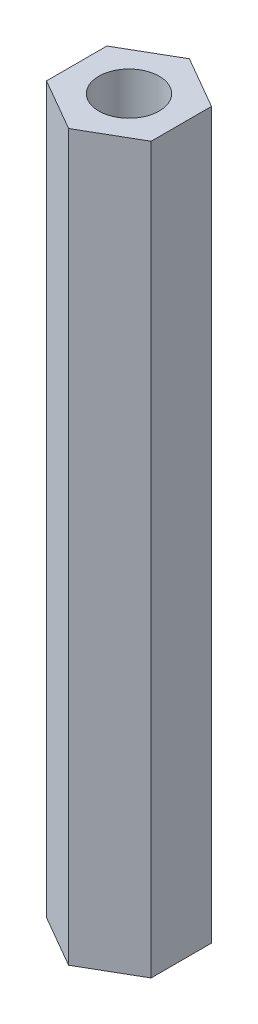
from build123d import *

# Parameters (mm, degrees)
ESQUISSE1_R      = 2.5
EXTRUSION1_DEPTH = 60


with BuildPart() as part:
    # Esquisse1 → Extrusion1 (new body)
    with BuildSketch(Plane(origin=(0, 0, 0), x_dir=(1, 0, 0), z_dir=(0, 1, 0))):
        Polygon((0, 5), (-4.330127019, 2.5), (-4.330127019, -2.5), (0, -5), (4.330127019, -2.5), (4.330127019, 2.5), align=None)
        Circle(ESQUISSE1_R, mode=Mode.SUBTRACT)
    extrude(amount=EXTRUSION1_DEPTH)


solid = part.part
